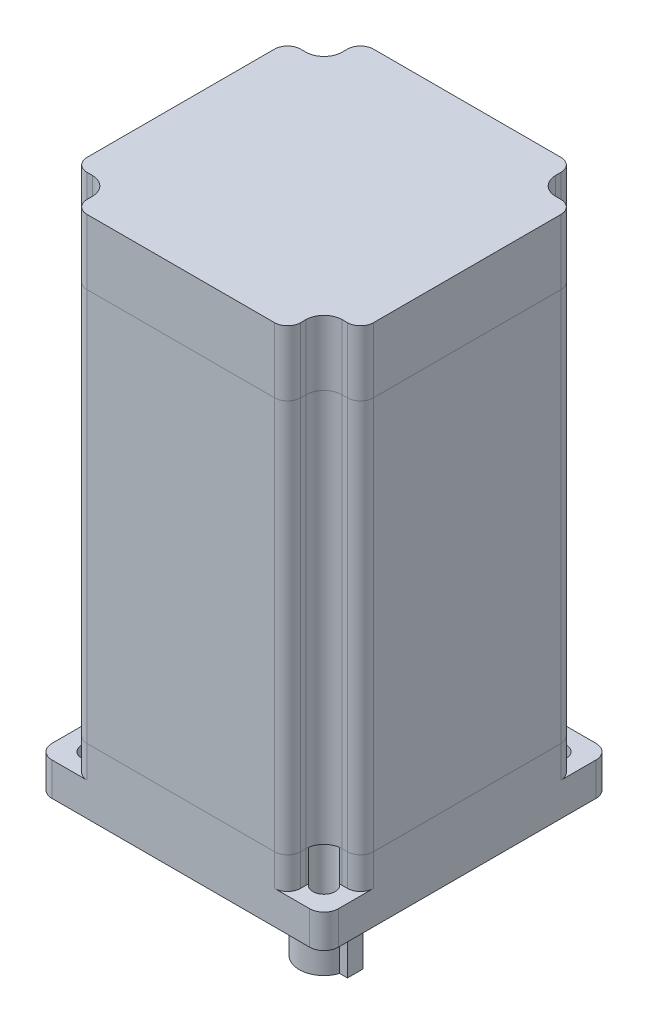
from build123d import *

# Parameters (mm, degrees)
SKETCH_1_W               = 110
SKETCH_1_H               = 110
EXTRUDE_1_DEPTH          = 151
CUT_EXTRUDE_1_DEPTH      = 152
PATTERN_CIRCULAR_1_COUNT = 4
EXTRUDE_2_DEPTH          = 25
EXTRUDE_4_DEPTH          = 25
CUT_EXTRUDE_2_DEPTH      = 12.2
PATTERN_CIRCULAR_2_COUNT = 4
SKETCH_9_R               = 27.75
EXTRUDE_5_DEPTH          = 1.5
SKETCH_15_R              = 8.75
CUT_EXTRUDE_7_DEPTH      = 2
SKETCH_11_R              = 9.5
EXTRUDE_6_DEPTH          = 55
SKETCH_12_R              = 4.25
CUT_EXTRUDE_3_DEPTH      = 202
CUT_EXTRUDE_8_DEPTH      = 2.5
EXTRUDE_7_DEPTH          = 5


with BuildPart() as part:
    # Sketch 1 → Extrude 1 (new body)
    with BuildSketch(Plane(origin=(0, 0, 0), x_dir=(1, 0, 0), z_dir=(0, 1, 0))):
        Rectangle(SKETCH_1_W, SKETCH_1_H)
    extrude(amount=EXTRUDE_1_DEPTH)

    # Sketch 3 → Cut-Extrude 1 (cut, through all)
    with BuildSketch(Plane(origin=(0, 151, 0), x_dir=(1, 0, 0), z_dir=(0, 1, 0))):
        with BuildLine():
            Line((-50, -41), (-48, -41))
            ThreePointArc((-48, -41), (-43.050252532, -43.050252532), (-41, -48))
            Line((-41, -48), (-41, -50))
            ThreePointArc((-41, -50), (-39.535533906, -53.535533906), (-36, -55))
            Line((-36, -55), (-55, -55))
            Line((-55, -55), (-55, -36))
            ThreePointArc((-55, -36), (-53.535533906, -39.535533906), (-50, -41))
        make_face()
    cut_extrude_1 = extrude(amount=-CUT_EXTRUDE_1_DEPTH, mode=Mode.SUBTRACT)

    # Pattern Circular 1: Cut-Extrude 1 ×4 about axis
    pattern_circular_1_axis = Axis((0, 0, 0), (0, 1, 0))
    for i in range(1, PATTERN_CIRCULAR_1_COUNT):
        add(cut_extrude_1.rotate(pattern_circular_1_axis, i * 360 / PATTERN_CIRCULAR_1_COUNT), mode=Mode.SUBTRACT)


with BuildPart() as body_2:
    # Sketch 4 → Extrude 2 (new body)
    with BuildSketch(Plane(origin=(0, 151, 0), x_dir=(1, 0, 0), z_dir=(0, 1, 0))):
        with BuildLine():
            Line((-55, 36), (-55, -36))
            ThreePointArc((-55, -36), (-53.535533906, -39.535533906), (-50, -41))
            Line((-50, -41), (-48, -41))
            ThreePointArc((-48, -41), (-43.050252532, -43.050252532), (-41, -48))
            Line((-41, -48), (-41, -50))
            ThreePointArc((-41, -50), (-39.535533906, -53.535533906), (-36, -55))
            Line((-36, -55), (36, -55))
            ThreePointArc((36, -55), (39.535533906, -53.535533906), (41, -50))
            Line((41, -50), (41, -48))
            ThreePointArc((41, -48), (43.050252532, -43.050252532), (48, -41))
            Line((48, -41), (50, -41))
            ThreePointArc((50, -41), (53.535533906, -39.535533906), (55, -36))
            Line((55, -36), (55, 36))
            ThreePointArc((55, 36), (53.535533906, 39.535533906), (50, 41))
            Line((50, 41), (48, 41))
            ThreePointArc((48, 41), (43.050252532, 43.050252532), (41, 48))
            Line((41, 48), (41, 50))
            ThreePointArc((41, 50), (39.535533906, 53.535533906), (36, 55))
            Line((36, 55), (-36, 55))
            ThreePointArc((-36, 55), (-39.535533906, 53.535533906), (-41, 50))
            Line((-41, 50), (-41, 48))
            ThreePointArc((-41, 48), (-43.050252532, 43.050252532), (-48, 41))
            Line((-48, 41), (-50, 41))
            ThreePointArc((-50, 41), (-53.535533906, 39.535533906), (-55, 36))
        make_face()
    extrude(amount=EXTRUDE_2_DEPTH)


with BuildPart() as body_3:
    # Sketch 6 → Extrude 4 (new body)
    with BuildSketch(Plane.XZ):
        with BuildLine():
            Line((-49.5, 55), (49.5, 55))
            ThreePointArc((49.5, 55), (53.389087297, 53.389087297), (55, 49.5))
            Line((55, 49.5), (55, -49.5))
            ThreePointArc((55, -49.5), (53.389087297, -53.389087297), (49.5, -55))
            Line((49.5, -55), (-49.5, -55))
            ThreePointArc((-49.5, -55), (-53.389087297, -53.389087297), (-55, -49.5))
            Line((-55, -49.5), (-55, 49.5))
            ThreePointArc((-55, 49.5), (-53.389087297, 53.389087297), (-49.5, 55))
        make_face()
    extrude(amount=EXTRUDE_4_DEPTH)

    # Sketch 8 → Cut-Extrude 2 (cut)
    with BuildSketch(Plane(origin=(0, 0, 0), x_dir=(1, 0, 0), z_dir=(0, 1, 0))):
        with BuildLine():
            Line((-50, -41), (-48, -41))
            ThreePointArc((-48, -41), (-43.050252532, -43.050252532), (-41, -48))
            Line((-41, -48), (-41, -50))
            ThreePointArc((-41, -50), (-39.535533906, -53.535533906), (-36, -55))
            Line((-36, -55), (-49.5, -55))
            ThreePointArc((-49.5, -55), (-53.389087297, -53.389087297), (-55, -49.5))
            Line((-55, -49.5), (-55, -36))
            ThreePointArc((-55, -36), (-53.535533906, -39.535533906), (-50, -41))
        make_face()
    cut_extrude_2 = extrude(amount=-CUT_EXTRUDE_2_DEPTH, mode=Mode.SUBTRACT)

    # Pattern Circular 2: Cut-Extrude 2 ×4 about axis
    pattern_circular_2_axis = Axis((0, 0, 0), (0, 1, 0))
    for i in range(1, PATTERN_CIRCULAR_2_COUNT):
        add(cut_extrude_2.rotate(pattern_circular_2_axis, i * 360 / PATTERN_CIRCULAR_2_COUNT), mode=Mode.SUBTRACT)

    # Sketch 9 → Extrude 5 (add)
    with BuildSketch(Plane.XZ.offset(25)):
        with Locations(Location((0, 0, 0), (0, 0, 270))):  # turned: the seam where the file's is
            Circle(SKETCH_9_R)
    extrude(amount=EXTRUDE_5_DEPTH)

    # Sketch 15 → Cut-Extrude 7 (cut)
    with BuildSketch(Plane.XZ.offset(26.5)):
        with Locations(Location((0, 0, 0), (0, 0, 270))):  # turned: the seam where the file's is
            Circle(SKETCH_15_R)
    extrude(amount=-CUT_EXTRUDE_7_DEPTH, mode=Mode.SUBTRACT)

    # Sketch 12 → Cut-Extrude 3 (cut, through all)
    with BuildSketch(Plane.XZ.offset(25)):
        with Locations(Location((-44.45, 44.45, 0), (0, 0, 270))):  # turned: the seam where the file's is
            Circle(SKETCH_12_R)
        with Locations(Location((44.45, 44.45, 0), (0, 0, 270))):  # turned: the seam where the file's is
            Circle(SKETCH_12_R)
        with Locations(Location((-44.45, -44.45, 0), (0, 0, 270))):  # turned: the seam where the file's is
            Circle(SKETCH_12_R)
        with Locations(Location((44.45, -44.45, 0), (0, 0, 270))):  # turned: the seam where the file's is
            Circle(SKETCH_12_R)
    extrude(amount=-CUT_EXTRUDE_3_DEPTH, mode=Mode.SUBTRACT)


with BuildPart() as body_4:
    # Sketch 11 → Extrude 6 (new body)
    with BuildSketch(Plane.XZ.offset(25)):
        with Locations(Location((0, 0, 0), (0, 0, 270))):  # turned: the seam where the file's is
            Circle(SKETCH_11_R)
    extrude(amount=EXTRUDE_6_DEPTH)

    # Sketch 16 → Cut-Extrude 8 (cut)
    with BuildSketch(Plane(origin=(9.5, 0, 0), x_dir=(0, 0, -1), z_dir=(1, 0, 0))):
        with BuildLine():
            Line((-3, -80), (-3, -47))
            ThreePointArc((-3, -47), (0, -44), (3, -47))
            Line((3, -47), (3, -80))
            Line((3, -80), (-3, -80))
        make_face()
    extrude(amount=-CUT_EXTRUDE_8_DEPTH, mode=Mode.SUBTRACT)


with BuildPart() as body_5:
    # Sketch 17 → Extrude 7 (new body)
    with BuildSketch(Plane(origin=(7, 0, 0), x_dir=(0, 0, -1), z_dir=(1, 0, 0))):
        with BuildLine():
            Line((-3, -80), (3, -80))
            Line((3, -80), (3, -47))
            ThreePointArc((3, -47), (0, -44), (-3, -47))
            Line((-3, -47), (-3, -80))
        make_face()
    extrude(amount=EXTRUDE_7_DEPTH)


solid = Compound([part.part, body_2.part, body_3.part, body_4.part, body_5.part])
